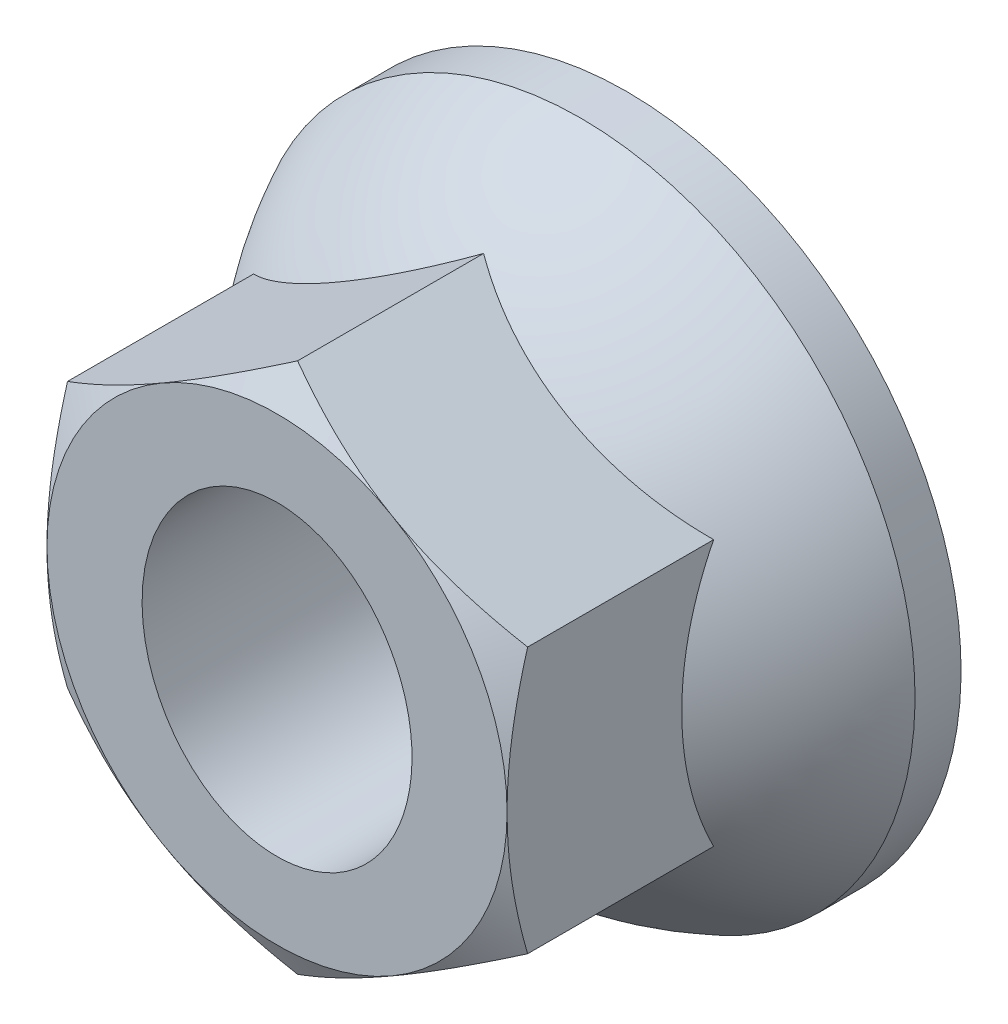
from build123d import *

# Parameters (mm, degrees)
EXTRUDE1_DEPTH      = 5.7
SKETCH2_OUTSIDE_W   = 73.328
SKETCH2_OUTSIDE_H   = 73.328
SKETCH2_OUTSIDE_R   = 7.5
CUT_EXTRUDE1_DEPTH  = 12.4
CUT_EXTRUDE1_TAPER  = 60
SKETCH5_R           = 5
CUT_EXTRUDE10_DEPTH = 12.4
SKETCH16_R          = 7.5
SKETCH16_RX         = 5
SKETCH16_RY         = 4.4
EXTRUDE2_DEPTH      = 11.4


with BuildPart() as part:
    # Sketch20 → Extrude1 (new body, symmetric)
    with BuildSketch(Plane.XY):
        Polygon((7.5, -4.330127019), (7.5, 4.330127019), (0, 8.660254038), (-7.5, 4.330127019), (-7.5, -4.330127019), (0, -8.660254038), align=None)
    extrude(amount=EXTRUDE1_DEPTH, both=True)

    # Sketch18 → Revolve1 (revolve)
    with BuildSketch(Plane(origin=(0, 0, 0), x_dir=(0, 0, -1), z_dir=(1, 0, 0))):
        with BuildLine():
            Line((5.7, 0), (5.7, 10.9))
            Line((5.7, 10.9), (4.2, 10.9))
            ThreePointArc((4.2, 10.9), (-0.760606441, 6.423589339), (-2.6, 0))
            Line((-2.6, 0), (5.7, 0))
        make_face()
    revolve(axis=Axis((0, 0, -5.7), (0, 0, 1)))

    # Sketch2 outside → Cut-Extrude1 (cut, through all)
    with BuildSketch(Plane.XY.offset(5.7)):
        Rectangle(SKETCH2_OUTSIDE_W, SKETCH2_OUTSIDE_H)
        Circle(SKETCH2_OUTSIDE_R, mode=Mode.SUBTRACT)
    extrude(amount=-CUT_EXTRUDE1_DEPTH, taper=CUT_EXTRUDE1_TAPER, mode=Mode.SUBTRACT)

    # Sketch5 → Cut-Extrude10 (cut, through all)
    with BuildSketch(Plane(origin=(0, 0, 5.7), x_dir=(-1, 0, 0), z_dir=(0, 0, -1))):
        Circle(SKETCH5_R)
    extrude(amount=CUT_EXTRUDE10_DEPTH, mode=Mode.SUBTRACT)

    # Sketch16 → Extrude2 (add)
    with BuildSketch(Plane.XY.offset(5.7)):
        Circle(SKETCH16_R)
        with Locations(Location((0, 0), (0, 0, 90))):
            Ellipse(SKETCH16_RX, SKETCH16_RY, mode=Mode.SUBTRACT)
    extrude(amount=-EXTRUDE2_DEPTH)


solid = part.part
